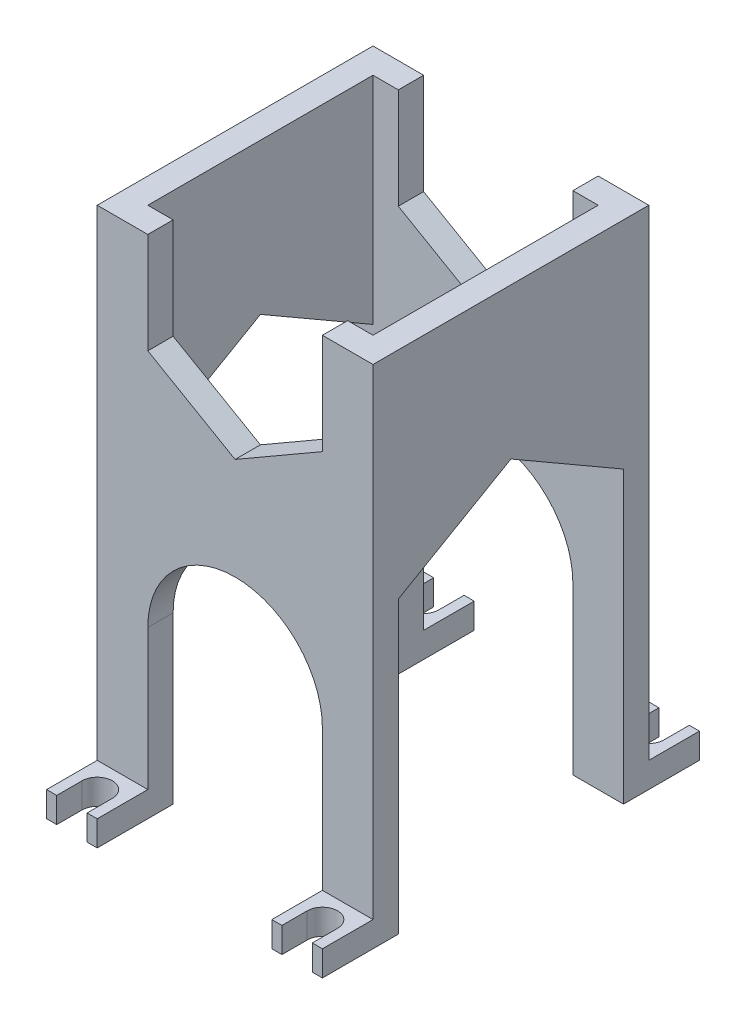
from build123d import *

# Parameters (mm, degrees)
ESQUISSE1_W             = 54.5
ESQUISSE1_H             = 54.5
BOSS_EXTRU_1_DEPTH      = 100
ENL_V_MAT_EXTRU_1_DEPTH = 55.5
ESQUISSE4_W             = 44.5
ESQUISSE4_H             = 44.5
ENL_V_MAT_EXTRU_3_DEPTH = 101
ENL_V_MAT_EXTRU_7_DEPTH = 55.5
BOSS_EXTRU_2_DEPTH      = 5


with BuildPart() as part:
    # Esquisse1 → Boss.-Extru.1 (new body)
    with BuildSketch(Plane(origin=(0, 0, 0), x_dir=(1, 0, 0), z_dir=(0, 1, 0))):
        Rectangle(ESQUISSE1_W, ESQUISSE1_H)
    extrude(amount=BOSS_EXTRU_1_DEPTH)

    # Esquisse2 → Enlèv. mat.-Extru.1 (cut, through all)
    with BuildSketch(Plane(origin=(27.25, 0, 0), x_dir=(0, 0, -1), z_dir=(1, 0, 0))):
        Polygon((-22.25, 0), (22.25, 0), (22.25, 44.5), (22.25, 57.346043489), (0, 70.192086979), (-22.25, 57.346043489), (-22.25, 44.5), align=None)
    extrude(amount=-ENL_V_MAT_EXTRU_1_DEPTH, mode=Mode.SUBTRACT)

    # Esquisse4 → Enlèv. mat.-Extru.3 (cut, through all)
    with BuildSketch(Plane(origin=(0, 100, 0), x_dir=(1, 0, 0), z_dir=(0, 1, 0))):
        Rectangle(ESQUISSE4_W, ESQUISSE4_H)
    extrude(amount=-ENL_V_MAT_EXTRU_3_DEPTH, mode=Mode.SUBTRACT)

    # Esquisse6 → Enlèv. mat.-Extru.7 (cut, through all)
    with BuildSketch(Plane(origin=(0, 0, -27.25), x_dir=(-1, 0, 0), z_dir=(0, 0, -1))):
        Polygon((0, 109.959292144), (-17.25, 100), (-17.25, 80.081415713), (0, 70.122123569), (17.25, 80.081415713), (17.25, 100), align=None)
        with BuildLine():
            Line((17.25, 0), (-17.25, 0))
            Line((-17.25, 0), (-17.25, 32.75))
            ThreePointArc((-17.25, 32.75), (0, 50), (17.25, 32.75))
            Line((17.25, 32.75), (17.25, 0))
        make_face()
    extrude(amount=-ENL_V_MAT_EXTRU_7_DEPTH, mode=Mode.SUBTRACT)

    # Esquisse11 → Boss.-Extru.2 (add)
    with BuildSketch(Plane(origin=(0, 0, 0), x_dir=(1, 0, 0), z_dir=(0, 1, 0))):
        with BuildLine():
            Line((19.25, 37.25), (19.25, 32.25))
            ThreePointArc((19.25, 32.25), (22.25, 29.25), (25.25, 32.25))
            Line((25.25, 32.25), (25.25, 37.25))
            Line((25.25, 37.25), (27.25, 37.25))
            Line((27.25, 37.25), (27.25, 22.25))
            Line((27.25, 22.25), (17.25, 22.25))
            Line((17.25, 22.25), (17.25, 37.25))
            Line((17.25, 37.25), (19.25, 37.25))
        make_face()
        with BuildLine():
            Line((-17.25, 22.25), (-27.25, 22.25))
            Line((-27.25, 22.25), (-27.25, 37.25))
            Line((-27.25, 37.25), (-25.25, 37.25))
            Line((-25.25, 37.25), (-25.25, 32.25))
            ThreePointArc((-25.25, 32.25), (-22.25, 29.25), (-19.25, 32.25))
            Line((-19.25, 32.25), (-19.25, 37.25))
            Line((-19.25, 37.25), (-17.25, 37.25))
            Line((-17.25, 37.25), (-17.25, 22.25))
        make_face()
        with BuildLine():
            Line((17.25, -22.25), (27.25, -22.25))
            Line((27.25, -22.25), (27.25, -37.25))
            Line((27.25, -37.25), (25.25, -37.25))
            Line((25.25, -37.25), (25.25, -32.25))
            ThreePointArc((25.25, -32.25), (22.25, -29.25), (19.25, -32.25))
            Line((19.25, -32.25), (19.25, -37.25))
            Line((19.25, -37.25), (17.25, -37.25))
            Line((17.25, -37.25), (17.25, -22.25))
        make_face()
        with BuildLine():
            Line((-19.25, -37.25), (-19.25, -32.25))
            ThreePointArc((-19.25, -32.25), (-22.25, -29.25), (-25.25, -32.25))
            Line((-25.25, -32.25), (-25.25, -37.25))
            Line((-25.25, -37.25), (-27.25, -37.25))
            Line((-27.25, -37.25), (-27.25, -22.25))
            Line((-27.25, -22.25), (-17.25, -22.25))
            Line((-17.25, -22.25), (-17.25, -37.25))
            Line((-17.25, -37.25), (-19.25, -37.25))
        make_face()
    extrude(amount=BOSS_EXTRU_2_DEPTH)


solid = part.part
